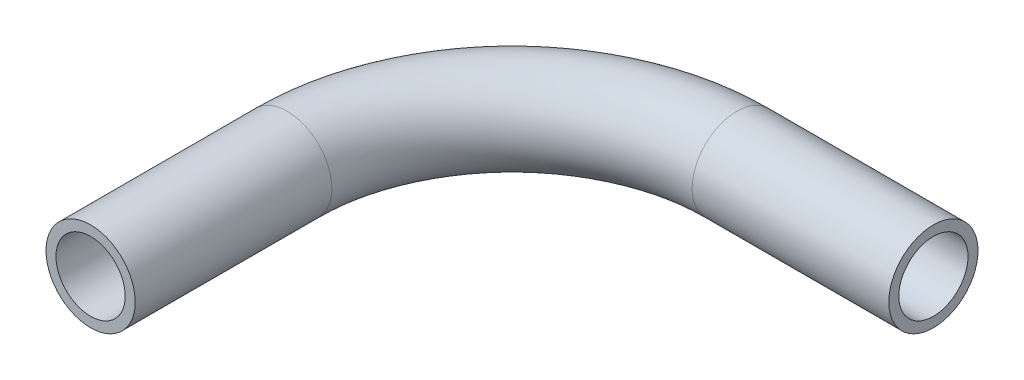
from build123d import *

# Parameters (mm, degrees)
SKETCH2_R   = 3.175
SKETCH2_R_2 = 2.4638


with BuildPart() as part:
    # Sweep-Thin1: sweep along a path in Sketch1
    with BuildLine(Plane(origin=(0, 0, 0), x_dir=(1, 0, 0), z_dir=(0, 1, 0))) as sweep_thin1_path:
        Line((0, 0), (0, 14))
        ThreePointArc((0, 14), (4.686291501, 25.313708499), (16, 30))
        Line((16, 30), (17.2, 30))
        Line((17.2, 30), (30, 30))
    # Sketch2 → Sweep-Thin1 (sweep)
    with BuildSketch(Plane.XY):
        Circle(SKETCH2_R)
        Circle(SKETCH2_R_2, mode=Mode.SUBTRACT)
    sweep(path=sweep_thin1_path.line)


solid = part.part
